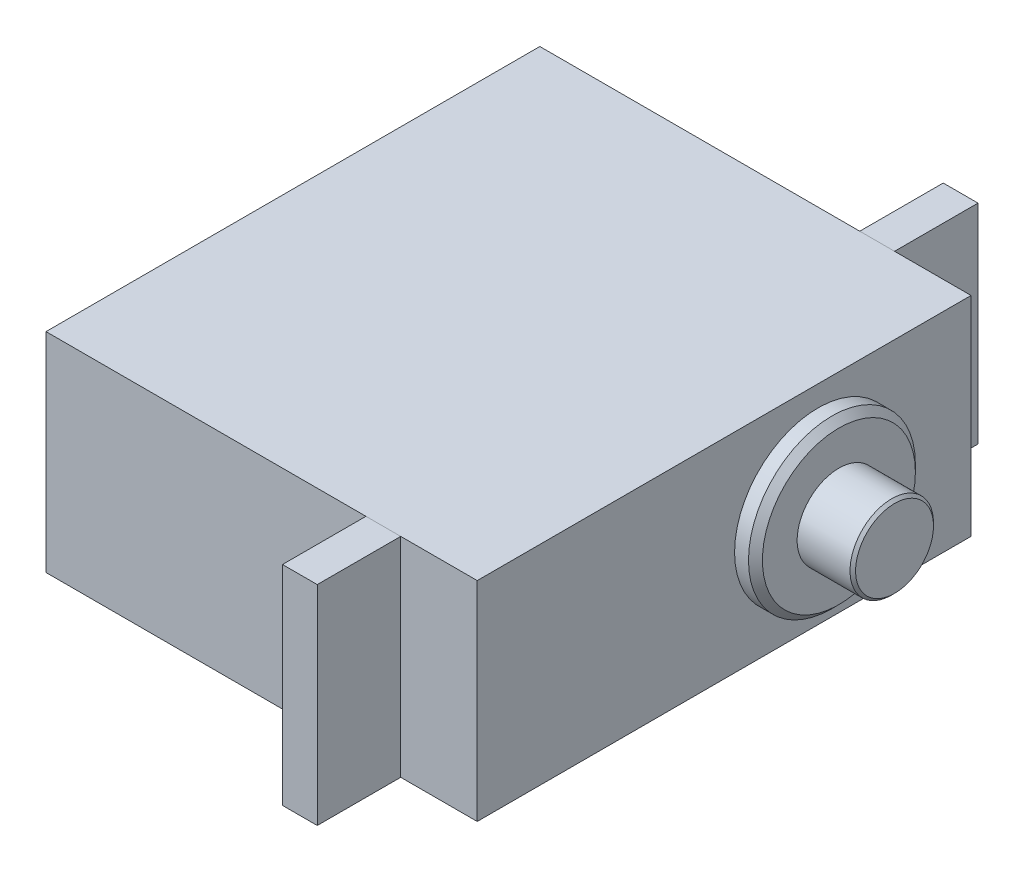
from build123d import *

# Parameters (mm, degrees)
SKETCH_2_W        = 35.5
SKETCH_2_H        = 15
EXTRUDE_1_DEPTH   = 31
SKETCH_3_W        = 2.5
SKETCH_3_H        = 6
EXTRUDE_2_DEPTH   = 15
EXTRUDE_2_2_DEPTH = 15
SKETCH_4_R        = 6
EXTRUDE_3_DEPTH   = 1.5
CHAMFER_1_SIZE    = 0.5
SKETCH_5_R        = 3
EXTRUDE_4_DEPTH   = 4
CHAMFER_2_SIZE    = 0.2


with BuildPart() as part:
    # 草图2 → 凸台-拉伸1 (new body)
    with BuildSketch(Plane(origin=(0, 0, 0), x_dir=(0, 0, -1), z_dir=(1, 0, 0))):
        Rectangle(SKETCH_2_W, SKETCH_2_H)
    extrude(amount=EXTRUDE_1_DEPTH)

    # 草图4 → 凸台-拉伸3 (add)
    with BuildSketch(Plane(origin=(31, 0, 0), x_dir=(0, 0, -1), z_dir=(1, 0, 0))):
        with Locations((6.75, 0)):
            Circle(SKETCH_4_R)
    extrude(amount=EXTRUDE_3_DEPTH)

    # 倒角1
    chamfer_1_edges = [part.edges().sort_by_distance(p)[0] for p in [
        (32.5, 0, -0.75),
    ]]
    chamfer(chamfer_1_edges, length=CHAMFER_1_SIZE)

    # 草图5 → 凸台-拉伸4 (add)
    with BuildSketch(Plane(origin=(32.5, 0, 0), x_dir=(0, 0, -1), z_dir=(1, 0, 0))):
        with Locations((6.75, 0)):
            Circle(SKETCH_5_R)
    extrude(amount=EXTRUDE_4_DEPTH)

    # 倒角2
    chamfer_2_edges = [part.edges().sort_by_distance(p)[0] for p in [
        (36.5, 0, -3.75),
    ]]
    chamfer(chamfer_2_edges, length=CHAMFER_2_SIZE)


with BuildPart() as body_2:
    # 草图3 → 凸台-拉伸2 (new body)
    with BuildSketch(Plane(origin=(0, 7.5, 0), x_dir=(1, 0, 0), z_dir=(0, 1, 0))):
        with Locations((24.25, 20.75)):
            Rectangle(SKETCH_3_W, SKETCH_3_H)
    extrude(amount=-EXTRUDE_2_DEPTH)


with BuildPart() as body_3:
    # 草图3 → Extrude 2 2 (new body)
    with BuildSketch(Plane(origin=(0, 7.5, 0), x_dir=(1, 0, 0), z_dir=(0, 1, 0))):
        with Locations((24.25, -20.75)):
            Rectangle(SKETCH_3_W, SKETCH_3_H)
    extrude(amount=-EXTRUDE_2_2_DEPTH)


solid = Compound([part.part, body_2.part, body_3.part])
